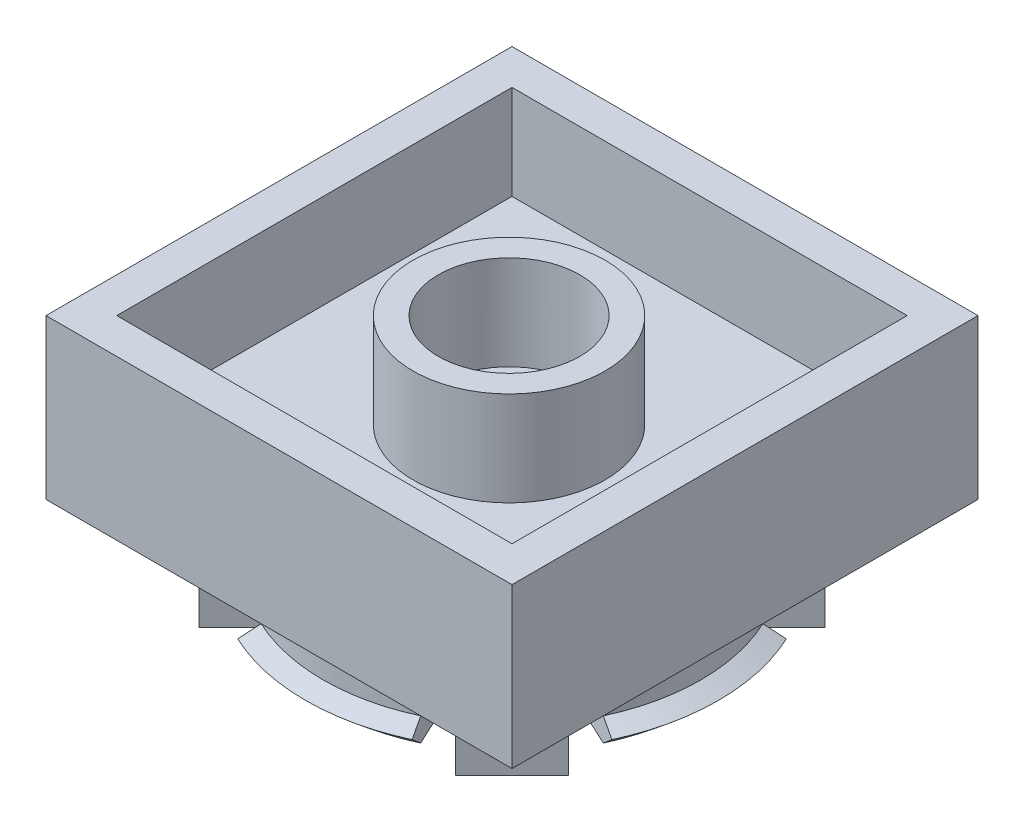
from build123d import *

# Parameters (mm, degrees)
SKETCH2_W           = 15.8
SKETCH2_H           = 15.8
BOSS_EXTRUDE2_DEPTH = 5.4
SKETCH4_W           = 13.4
SKETCH4_H           = 13.4
CUT_EXTRUDE1_DEPTH  = 3.2
SKETCH7_R           = 3.255
SKETCH7_R_2         = 2.4
BOSS_EXTRUDE5_DEPTH = 3.2
SKETCH8_R           = 5.15
CUT_EXTRUDE2_DEPTH  = 0.3
BOSS_EXTRUDE8_DEPTH = 2.8
CIRPATTERN1_COUNT   = 4
BOSS_EXTRUDE9_DEPTH = 2.9
REVOLVE4_ANGLE      = 50
CIRPATTERN9_COUNT   = 4


with BuildPart() as part:
    # Sketch2 → Boss-Extrude2 (new body)
    with BuildSketch(Plane(origin=(0, 0, 0), x_dir=(1, 0, 0), z_dir=(0, 1, 0))):
        with Locations((7.9, 7.9)):
            Rectangle(SKETCH2_W, SKETCH2_H)
    extrude(amount=-BOSS_EXTRUDE2_DEPTH)

    # Sketch4 → Cut-Extrude1 (cut)
    with BuildSketch(Plane(origin=(0, 0, 0), x_dir=(1, 0, 0), z_dir=(0, 1, 0))):
        with Locations((7.9, 7.9)):
            Rectangle(SKETCH4_W, SKETCH4_H)
    extrude(amount=-CUT_EXTRUDE1_DEPTH, mode=Mode.SUBTRACT)

    # Sketch7 → Boss-Extrude5 (add)
    with BuildSketch(Plane(origin=(0, -3.2, 0), x_dir=(1, 0, 0), z_dir=(0, 1, 0))):
        with Locations((7.85, 7.85)):
            Circle(SKETCH7_R)
        with Locations((7.85, 7.85)):
            Circle(SKETCH7_R_2, mode=Mode.SUBTRACT)
    extrude(amount=BOSS_EXTRUDE5_DEPTH)

    # Sketch8 → Cut-Extrude2 (cut)
    with BuildSketch(Plane(origin=(0, -5.4, 0), x_dir=(-1, 0, 0), z_dir=(0, -1, 0))):
        with Locations((-7.9, 7.9)):
            Circle(SKETCH8_R)
    extrude(amount=-CUT_EXTRUDE2_DEPTH, mode=Mode.SUBTRACT)

    # Sketch11 → Boss-Extrude8 (add)
    with BuildSketch(Plane.XZ.offset(5.4)):
        Polygon((11.683021279, -2.207790411), (12.637615434, -3.162384566), (13.203300859, -2.596699141), (12.248706704, -1.642104986), align=None)
        with BuildLine():
            ThreePointArc((11.585853022, -2.304958669), (12.133497372, -2.706975833), (12.637615434, -3.162384566))
            Line((12.637615434, -3.162384566), (11.683021279, -2.207790411))
            Line((11.683021279, -2.207790411), (11.585853022, -2.304958669))
        make_face()
        with BuildLine():
            ThreePointArc((10.459662524, -3.431149167), (11.028098464, -3.808851017), (11.541599923, -4.258400077))
            Line((11.541599923, -4.258400077), (12.637615434, -3.162384566))
            ThreePointArc((12.637615434, -3.162384566), (12.133497372, -2.706975833), (11.585853022, -2.304958669))
            Line((11.585853022, -2.304958669), (10.459662524, -3.431149167))
        make_face()
        with BuildLine():
            Line((12.637615434, -3.162384566), (11.541599923, -4.258400077))
            ThreePointArc((11.541599923, -4.258400077), (11.991148983, -4.771901536), (12.368850833, -5.340337476))
            Line((12.368850833, -5.340337476), (13.495041331, -4.214146978))
            ThreePointArc((13.495041331, -4.214146978), (13.093024167, -3.666502628), (12.637615434, -3.162384566))
        make_face()
        with BuildLine():
            Line((13.592209589, -4.116978721), (12.637615434, -3.162384566))
            ThreePointArc((12.637615434, -3.162384566), (13.093024167, -3.666502628), (13.495041331, -4.214146978))
            Line((13.495041331, -4.214146978), (13.592209589, -4.116978721))
        make_face()
        Polygon((13.203300859, -2.596699141), (12.637615434, -3.162384566), (13.592209589, -4.116978721), (14.157895014, -3.551293296), align=None)
    boss_extrude8 = extrude(amount=BOSS_EXTRUDE8_DEPTH)

    # CirPattern1: Boss-Extrude8 ×4 about axis
    cirpattern1_axis = Axis((7.9, 0, -7.9), (0, 1, 0))
    for i in range(1, CIRPATTERN1_COUNT):
        add(boss_extrude8.rotate(cirpattern1_axis, i * 360 / CIRPATTERN1_COUNT))

    # Sketch12 → Boss-Extrude9 (add)
    with BuildSketch(Plane.XZ.offset(5.4)):
        with BuildLine():
            Line((13.700369837, -5.195243125), (12.79406205, -5.617861387))
            ThreePointArc((12.79406205, -5.617861387), (13.3, -7.9), (12.79406205, -10.182138613))
            Line((12.79406205, -10.182138613), (13.700369837, -10.604756875))
            ThreePointArc((13.700369837, -10.604756875), (14.3, -7.9), (13.700369837, -5.195243125))
        make_face()
        with BuildLine():
            Line((10.604756875, -13.700369837), (10.182138613, -12.79406205))
            ThreePointArc((10.182138613, -12.79406205), (7.9, -13.3), (5.617861387, -12.79406205))
            Line((5.617861387, -12.79406205), (5.195243125, -13.700369837))
            ThreePointArc((5.195243125, -13.700369837), (7.9, -14.3), (10.604756875, -13.700369837))
        make_face()
        with BuildLine():
            Line((2.099630163, -10.604756875), (3.00593795, -10.182138613))
            ThreePointArc((3.00593795, -10.182138613), (2.5, -7.9), (3.00593795, -5.617861387))
            Line((3.00593795, -5.617861387), (2.099630163, -5.195243125))
            ThreePointArc((2.099630163, -5.195243125), (1.5, -7.9), (2.099630163, -10.604756875))
        make_face()
        with BuildLine():
            Line((5.195243125, -2.099630163), (5.617861387, -3.00593795))
            ThreePointArc((5.617861387, -3.00593795), (7.9, -2.5), (10.182138613, -3.00593795))
            Line((10.182138613, -3.00593795), (10.604756875, -2.099630163))
            ThreePointArc((10.604756875, -2.099630163), (7.9, -1.5), (5.195243125, -2.099630163))
        make_face()
    extrude(amount=BOSS_EXTRUDE9_DEPTH)

    # Sketch26 → Revolve4 (revolve)
    with BuildSketch(Plane(origin=(4.436864492, 0, -9.514886609), x_dir=(0.906307787, 0, 0.422618262), z_dir=(-0.422618262, 0, 0.906307787))):
        Polygon((10.22114725, -7.5), (10.82114725, -7.8), (10.22114725, -8.3), align=None)
    revolve4 = revolve(axis=Axis((7.9, -5.1, -7.9), (0, 1, 0)), revolution_arc=REVOLVE4_ANGLE)

    # CirPattern9: Revolve4 ×4 about axis
    cirpattern9_axis = Axis((7.9, -5.1, -7.9), (0, -1, 0))
    for i in range(1, CIRPATTERN9_COUNT):
        add(revolve4.rotate(cirpattern9_axis, i * 360 / CIRPATTERN9_COUNT))


solid = part.part
